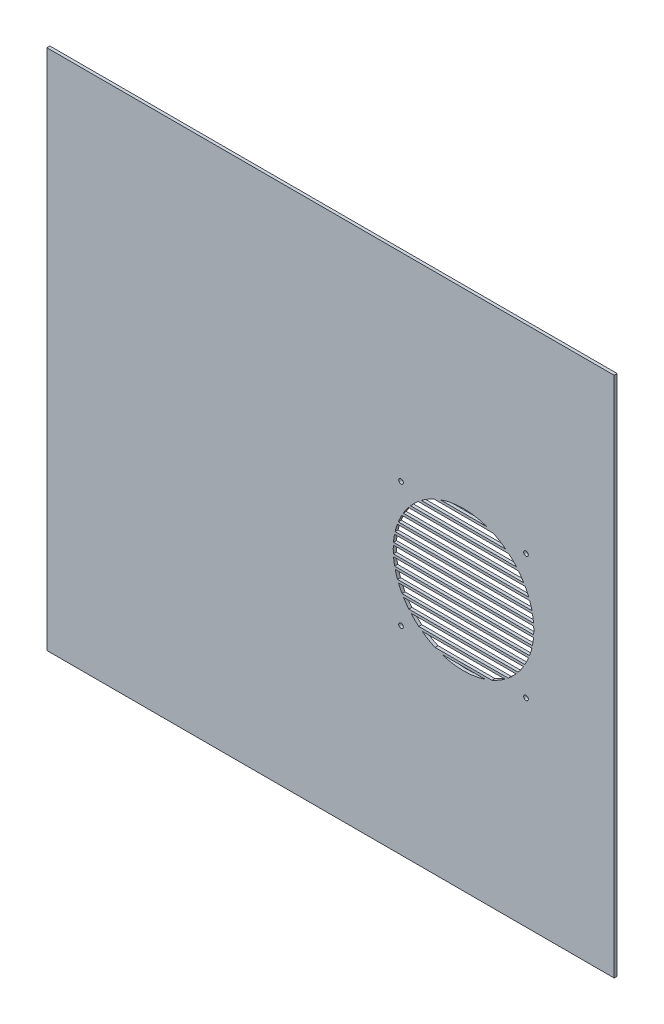
from build123d import *

# Parameters (mm, degrees)
SKICA1_W                = 565
SKICA1_H                = 520
SKICA1_R                = 2.3
P_IDAT_VYSUNUT_M1_DEPTH = 3


with BuildPart() as part:
    # Skica1 → Přidat vysunutím1 (new body)
    with BuildSketch(Plane.XY):
        Rectangle(SKICA1_W, SKICA1_H)
        with BuildLine():
            Line((177.042114903, -54), (87.957885097, -54))
            ThreePointArc((87.957885097, -54), (83.922227703, -50.400397207), (80.176487121, -46.5))
            Line((80.176487121, -46.5), (184.823512879, -46.5))
            ThreePointArc((184.823512879, -46.5), (181.077772297, -50.400397207), (177.042114903, -54))
        make_face(mode=Mode.SUBTRACT)
        with BuildLine():
            Line((91.175068058, -56.5), (173.824931942, -56.5))
            ThreePointArc((173.824931942, -56.5), (167.541147632, -60.598003042), (160.854893758, -64))
            Line((160.854893758, -64), (104.145106242, -64))
            ThreePointArc((104.145106242, -64), (97.458852368, -60.598003042), (91.175068058, -56.5))
        make_face(mode=Mode.SUBTRACT)
        with BuildLine():
            ThreePointArc((192.230645401, -36.5), (189.709673345, -40.336748453), (186.942630355, -44))
            Line((186.942630355, -44), (78.057369645, -44))
            ThreePointArc((78.057369645, -44), (75.290326655, -40.336748453), (72.769354599, -36.5))
            Line((72.769354599, -36.5), (192.230645401, -36.5))
        make_face(mode=Mode.SUBTRACT)
        with BuildLine():
            ThreePointArc((197.290045532, -26.5), (195.600667498, -30.303560208), (193.688234163, -34))
            Line((193.688234163, -34), (71.311765837, -34))
            ThreePointArc((71.311765837, -34), (69.399332502, -30.303560208), (67.709954468, -26.5))
            Line((67.709954468, -26.5), (197.290045532, -26.5))
        make_face(mode=Mode.SUBTRACT)
        with BuildLine():
            ThreePointArc((200.527567941, -16.5), (199.497378879, -20.281795369), (198.257128891, -24))
            Line((198.257128891, -24), (66.742871109, -24))
            ThreePointArc((66.742871109, -24), (65.502621121, -20.281795369), (64.472432059, -16.5))
            Line((64.472432059, -16.5), (200.527567941, -16.5))
        make_face(mode=Mode.SUBTRACT)
        with BuildLine():
            ThreePointArc((202.197560933, -6.5), (201.743255617, -10.265064616), (201.085712798, -14))
            Line((201.085712798, -14), (63.914287202, -14))
            ThreePointArc((63.914287202, -14), (63.256744383, -10.265064616), (62.802439067, -6.5))
            Line((62.802439067, -6.5), (202.197560933, -6.5))
        make_face(mode=Mode.SUBTRACT)
        with BuildLine():
            Line((202.385620839, -4), (62.614379161, -4))
            ThreePointArc((62.614379161, -4), (62.500447715, -0.250359516), (62.587554756, 3.5))
            Line((62.587554756, 3.5), (202.412445244, 3.5))
            ThreePointArc((202.412445244, 3.5), (202.499552285, -0.250359516), (202.385620839, -4))
        make_face(mode=Mode.SUBTRACT)
        with BuildLine():
            ThreePointArc((201.185879189, 13.5), (201.815643616, 9.764299777), (202.242383097, 6))
            Line((202.242383097, 6), (62.757616903, 6))
            ThreePointArc((62.757616903, 6), (63.184356384, 9.764299777), (63.814120811, 13.5))
            Line((63.814120811, 13.5), (201.185879189, 13.5))
        make_face(mode=Mode.SUBTRACT)
        with BuildLine():
            ThreePointArc((198.437470379, 23.5), (199.646981355, 19.780871947), (200.64690015, 16))
            Line((200.64690015, 16), (64.35309985, 16))
            ThreePointArc((64.35309985, 16), (65.353018645, 19.780871947), (66.562529621, 23.5))
            Line((66.562529621, 23.5), (198.437470379, 23.5))
        make_face(mode=Mode.SUBTRACT)
        with BuildLine():
            ThreePointArc((193.963403746, 33.5), (195.838962812, 29.802278268), (197.492307237, 26))
            Line((197.492307237, 26), (67.507692763, 26))
            ThreePointArc((67.507692763, 26), (69.161037188, 29.802278268), (71.036596254, 33.5))
            Line((71.036596254, 33.5), (193.963403746, 33.5))
        make_face(mode=Mode.SUBTRACT)
        with BuildLine():
            ThreePointArc((187.342957615, 43.5), (190.060424981, 39.834626596), (192.533324079, 36))
            Line((192.533324079, 36), (72.466675921, 36))
            ThreePointArc((72.466675921, 36), (74.939575019, 39.834626596), (77.657042385, 43.5))
            Line((77.657042385, 43.5), (187.342957615, 43.5))
        make_face(mode=Mode.SUBTRACT)
        with BuildLine():
            ThreePointArc((177.641444372, 53.5), (181.595958032, 49.89576039), (185.263623833, 46))
            Line((185.263623833, 46), (79.736376167, 46))
            ThreePointArc((79.736376167, 46), (83.404041968, 49.89576039), (87.358555628, 53.5))
            Line((87.358555628, 53.5), (177.641444372, 53.5))
        make_face(mode=Mode.SUBTRACT)
        with BuildLine():
            ThreePointArc((161.957596643, 63.5), (168.425054342, 60.078202957), (174.5, 56))
            Line((174.5, 56), (90.5, 56))
            ThreePointArc((90.5, 56), (96.574945658, 60.078202957), (103.042403357, 63.5))
            Line((103.042403357, 63.5), (161.957596643, 63.5))
        make_face(mode=Mode.SUBTRACT)
        with Locations((194.75, 62.25)):
            Circle(SKICA1_R, mode=Mode.SUBTRACT)
        with BuildLine():
            ThreePointArc((109.176192421, 66), (132.5, 70), (155.823807579, 66))
            Line((155.823807579, 66), (109.176192421, 66))
        make_face(mode=Mode.SUBTRACT)
        with Locations((70.25, 62.25)):
            Circle(SKICA1_R, mode=Mode.SUBTRACT)
        with Locations((194.75, -62.25)):
            Circle(SKICA1_R, mode=Mode.SUBTRACT)
        with Locations((70.25, -62.25)):
            Circle(SKICA1_R, mode=Mode.SUBTRACT)
        with BuildLine():
            ThreePointArc((154.357492994, -66.5), (132.5, -70), (110.642507006, -66.5))
            Line((110.642507006, -66.5), (154.357492994, -66.5))
        make_face(mode=Mode.SUBTRACT)
    extrude(amount=P_IDAT_VYSUNUT_M1_DEPTH)


solid = part.part
